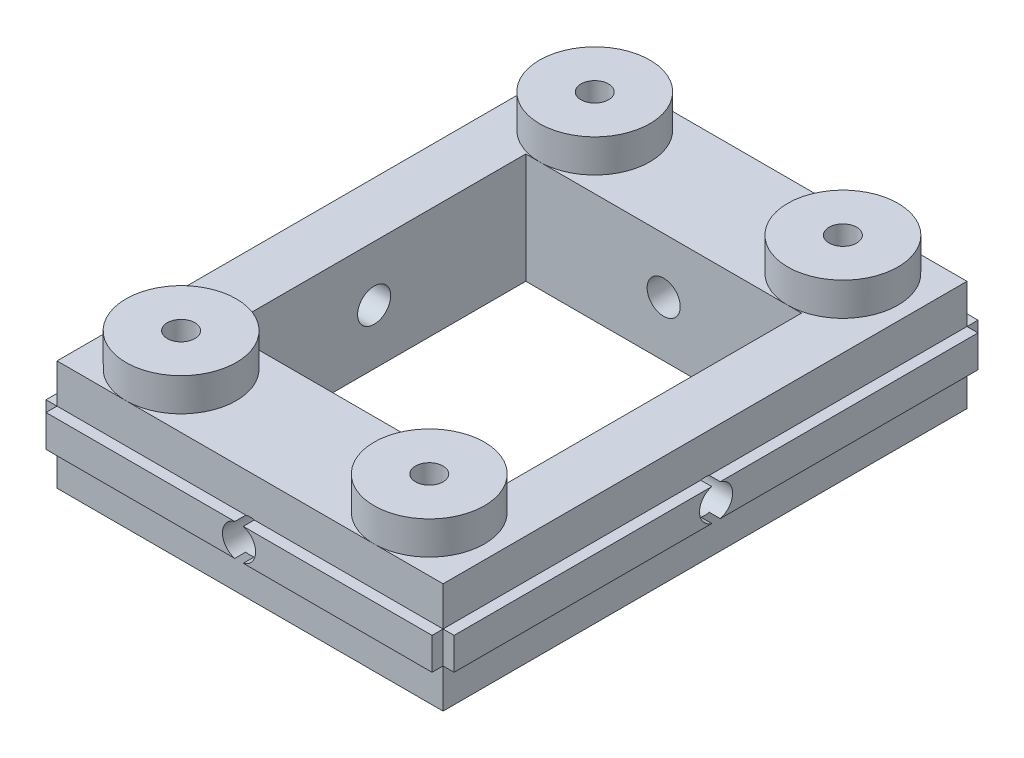
from build123d import *

# Parameters (mm, degrees)
MAIN_DEPTH               = 23.75
SKETCH2_R                = 5
SKETCH2_R_2              = 1.25
PLOT_DEPTH               = 3
SKETCH4_R                = 1.25
FIXHOLE_DEPTH            = 32.722428974
SKETCH3_W                = 25
SKETCH3_H                = 27.5
CENTRALHOLE_DEPTH        = 32.722428974
SKETCH5_R                = 1.5
MAKERBEAMFIXHOLE_DEPTH   = 45.688505233
SKETCH6_W                = 35
SKETCH6_H                = 2.9
MAKERBEAMOTHERRAIL_DEPTH = 1
SKETCH7_R                = 1.5
CUT_EXTRUDE4_DEPTH       = 54.446234666


with BuildPart() as part:
    # Sketch1 → Main (new, symmetric)
    with BuildSketch(Plane.XY):
        Polygon((-17.5, 5), (-17.5, 1.45), (-18.5, 1.45), (-18.5, -1.45), (-17.5, -1.45), (-17.5, -5), (17.5, -5), (17.5, -1.45), (18.5, -1.45), (18.5, 1.45), (17.5, 1.45), (17.5, 5), align=None)
    extrude(amount=MAIN_DEPTH, both=True)

    # Sketch2 → Plot (add)
    # profile 1 of 4: a face of its own
    with BuildSketch(Plane(origin=(0, 5, 0), x_dir=(1, 0, 0), z_dir=(0, 1, 0))):
        with Locations((-11.25, 18.75)):
            Circle(SKETCH2_R)
        with Locations((-11.25, 18.75)):
            Circle(SKETCH2_R_2, mode=Mode.SUBTRACT)
    # profile 2 of 4: a face of its own
    with BuildSketch(Plane(origin=(0, 5, 0), x_dir=(1, 0, 0), z_dir=(0, 1, 0))):
        with Locations((-11.25, -18.75)):
            Circle(SKETCH2_R)
        with Locations((-11.25, -18.75)):
            Circle(SKETCH2_R_2, mode=Mode.SUBTRACT)
    # profile 3 of 4: a face of its own
    with BuildSketch(Plane(origin=(0, 5, 0), x_dir=(1, 0, 0), z_dir=(0, 1, 0))):
        with Locations((11.25, 18.75)):
            Circle(SKETCH2_R)
        with Locations((11.25, 18.75)):
            Circle(SKETCH2_R_2, mode=Mode.SUBTRACT)
    # profile 4 of 4: a face of its own
    with BuildSketch(Plane(origin=(0, 5, 0), x_dir=(1, 0, 0), z_dir=(0, 1, 0))):
        with Locations((11.25, -18.75)):
            Circle(SKETCH2_R)
        with Locations((11.25, -18.75)):
            Circle(SKETCH2_R_2, mode=Mode.SUBTRACT)
    extrude(amount=PLOT_DEPTH)

    # Sketch4 → FixHole (cut, through all)
    with BuildSketch(Plane(origin=(0, 5, 0), x_dir=(1, 0, 0), z_dir=(0, 1, 0))):
        with Locations((-11.25, 18.75)):
            Circle(SKETCH4_R)
        with Locations((11.25, 18.75)):
            Circle(SKETCH4_R)
        with Locations((11.25, -18.75)):
            Circle(SKETCH4_R)
        with Locations((-11.25, -18.75)):
            Circle(SKETCH4_R)
    extrude(amount=-FIXHOLE_DEPTH, mode=Mode.SUBTRACT)

    # Sketch3 → CentralHole (cut, through all)
    with BuildSketch(Plane(origin=(0, 5, 0), x_dir=(1, 0, 0), z_dir=(0, 1, 0))):
        Rectangle(SKETCH3_W, SKETCH3_H)
    extrude(amount=-CENTRALHOLE_DEPTH, mode=Mode.SUBTRACT)

    # Sketch5 → MakerBeamFixHole (cut, through all)
    with BuildSketch(Plane.ZY.offset(18.5)):
        Circle(SKETCH5_R)
    extrude(amount=-MAKERBEAMFIXHOLE_DEPTH, mode=Mode.SUBTRACT)

    # Sketch6 → MakerBeamOtherRail (add)
    with BuildSketch(Plane.XY.offset(23.75)):
        Rectangle(SKETCH6_W, SKETCH6_H)
    makerbeamotherrail = extrude(amount=MAKERBEAMOTHERRAIL_DEPTH)

    # Mirror5: MakerBeamOtherRail across plane
    add(makerbeamotherrail.mirror(Plane.XY))

    # Sketch7 → Cut-Extrude4 (cut, through all)
    with BuildSketch(Plane.XY.offset(24.75)):
        Circle(SKETCH7_R)
    extrude(amount=-CUT_EXTRUDE4_DEPTH, mode=Mode.SUBTRACT)


solid = part.part
